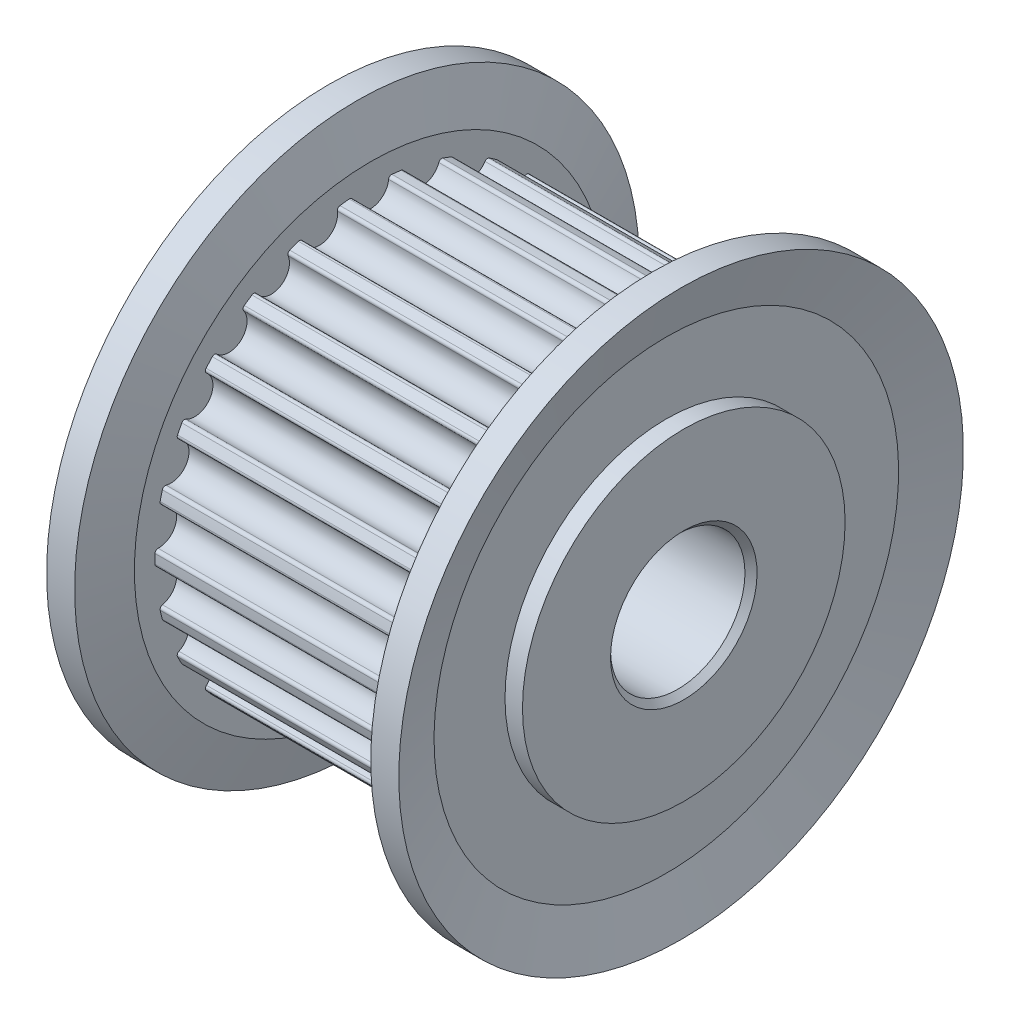
from build123d import *

# Parameters (mm, degrees)
CUT_EXTRUDE1_DEPTH = 33.733366768
CIRPATTERN1_COUNT  = 26


with BuildPart() as part:
    # Sketch1 → Revolve1 (revolve)
    with BuildSketch(Plane.XY):
        Polygon((-6, 6), (-6.65, 6), (-6.65, 2.725), (-6.425, 2.5), (6.425, 2.5), (6.65, 2.725), (6.65, 6), (6, 6), (5, 6), (5, 8.02), (-5, 8.02), (-5, 6), align=None)
    revolve(axis=Axis((17.85, 0, 0), (-1, 0, 0)))

    # Sketch5 → Cut-Extrude1 (cut, through all)
    with BuildSketch(Plane(origin=(-5, 0, -21.5), x_dir=(0, 0, 1), z_dir=(-1, 0, 0))):
        with BuildLine():
            Line((19, 7.620393691), (19, 7.888322065))
            ThreePointArc((19, 7.888322065), (21.5, 8.275), (24, 7.888322065))
            Line((24, 7.888322065), (24, 7.620393691))
            ThreePointArc((24, 7.620393691), (23.15727635, 7.846899713), (22.294932233, 7.980506422))
            ThreePointArc((22.294932233, 7.980506422), (22.212418714, 7.955529493), (22.171812608, 7.879480351))
            ThreePointArc((22.171812608, 7.879480351), (21.5, 7.26999997), (20.828187392, 7.879480351))
            ThreePointArc((20.828187392, 7.879480351), (20.787581286, 7.955529493), (20.705067767, 7.980506422))
            ThreePointArc((20.705067767, 7.980506422), (19.84272365, 7.846899713), (19, 7.620393691))
        make_face()
    cut_extrude1 = extrude(amount=-CUT_EXTRUDE1_DEPTH, mode=Mode.SUBTRACT)

    # CirPattern1: Cut-Extrude1 ×26 about axis
    cirpattern1_axis = Axis((17.85, 0, 0), (1, 0, 0))
    for i in range(1, CIRPATTERN1_COUNT):
        add(cut_extrude1.rotate(cirpattern1_axis, i * 360 / CIRPATTERN1_COUNT), mode=Mode.SUBTRACT)


with BuildPart() as body_2:
    # Sketch1_4 → Revolve2 (revolve)
    with BuildSketch(Plane.XY):
        Polygon((-6, 8.64), (-6, 6), (-5, 6), (-5, 8.78475157), (-5.507197116, 10.5), (-6.55, 10.5), align=None)
        Polygon((5, 8.78475157), (5, 6), (6, 6), (6, 8.64), (6.55, 10.5), (5.507197116, 10.5), align=None)
    revolve(axis=Axis((17.85, 0, 0), (-1, 0, 0)))


solid = Compound([part.part, body_2.part])
